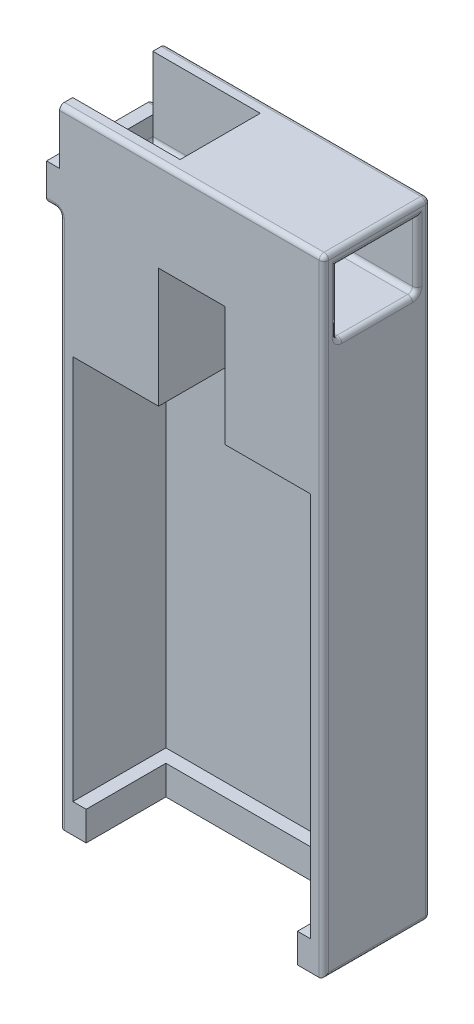
from build123d import *

# Parameters (mm, degrees)
SKETCH1_W            = 2.54
SKETCH1_H            = 2.54
BOSS_EXTRUDE3_DEPTH  = 5.588
BOSS_EXTRUDE4_START  = 5.588
BOSS_EXTRUDE4_DEPTH  = 73.66
BOSS_EXTRUDE6_START  = 79.248
SKETCH1_8_W          = 2.54
SKETCH1_8_H          = 2.54
SKETCH1_8_W_2        = 13.843
BOSS_EXTRUDE6_DEPTH  = 22.86
BOSS_EXTRUDE7_START  = 102.108
SKETCH1_9_W          = 12.7
SKETCH1_9_H          = 2.54
SKETCH1_9_W_2        = 2.54
SKETCH1_9_W_3        = 13.843
BOSS_EXTRUDE7_DEPTH  = 2.54
SKETCH2_W            = 50.546
SKETCH2_H            = 2.5
BOSS_EXTRUDE8_DEPTH  = 15
BOSS_EXTRUDE9_REACH  = 19.82
SKETCH3_W            = 30
SKETCH3_H            = 2.5
SKETCH4_W            = 20.32
SKETCH4_H            = 7
BOSS_EXTRUDE10_DEPTH = 2.5
FILLET1_R            = 0.905


with BuildPart() as part:
    # Sketch1 → Boss-Extrude3 (new body)
    with BuildSketch(Plane(origin=(0, 0, 0), x_dir=(1, 0, 0), z_dir=(0, 1, 0))):
        with BuildLine():
            Line((-22.733, -10.16), (-22.733, -7.62))
            Line((-22.733, -7.62), (-22.733, 7.62))
            Line((-22.733, 7.62), (-5.08, 7.62))
            ThreePointArc((-5.08, 7.62), (-2.839806331, 9.489612663), (0, 10.16))
            Line((0, 10.16), (-25.273, 10.16))
            Line((-25.273, 10.16), (-25.273, -10.16))
            Line((-25.273, -10.16), (-22.733, -10.16))
        make_face()
        with BuildLine():
            ThreePointArc((0, 10.16), (2.839806331, 9.489612663), (5.08, 7.62))
            Line((5.08, 7.62), (22.733, 7.62))
            Line((22.733, 7.62), (22.733, -7.62))
            Line((22.733, -7.62), (22.733, -10.16))
            Line((22.733, -10.16), (25.273, -10.16))
            Line((25.273, -10.16), (25.273, 10.16))
            Line((25.273, 10.16), (0, 10.16))
        make_face()
        with BuildLine():
            ThreePointArc((0, 10.16), (-2.839806331, 9.489612663), (-5.08, 7.62))
            Line((-5.08, 7.62), (5.08, 7.62))
            ThreePointArc((5.08, 7.62), (2.839806331, 9.489612663), (0, 10.16))
        make_face()
        with BuildLine():
            Line((-22.733, 7.62), (-22.733, -7.62))
            Line((-22.733, -7.62), (-20.193, -7.62))
            Line((-20.193, -7.62), (-20.193, -5.08))
            Line((-20.193, -5.08), (-20.193, 5.08))
            Line((-20.193, 5.08), (-6.221703947, 5.08))
            ThreePointArc((-6.221703947, 5.08), (-5.791806974, 6.413357827), (-5.08, 7.62))
            Line((-5.08, 7.62), (-22.733, 7.62))
        make_face()
        with Locations((-21.463, -8.89)):
            Rectangle(SKETCH1_W, SKETCH1_H)
        with BuildLine():
            Line((5.08, 7.62), (-5.08, 7.62))
            ThreePointArc((-5.08, 7.62), (-5.791806974, 6.413357827), (-6.221703947, 5.08))
            Line((-6.221703947, 5.08), (6.221703947, 5.08))
            ThreePointArc((6.221703947, 5.08), (5.791806974, 6.413357827), (5.08, 7.62))
        make_face()
        with BuildLine():
            Line((22.733, 7.62), (5.08, 7.62))
            ThreePointArc((5.08, 7.62), (5.791806974, 6.413357827), (6.221703947, 5.08))
            Line((6.221703947, 5.08), (20.193, 5.08))
            Line((20.193, 5.08), (20.193, -5.08))
            Line((20.193, -5.08), (20.193, -7.62))
            Line((20.193, -7.62), (22.733, -7.62))
            Line((22.733, -7.62), (22.733, 7.62))
        make_face()
        with Locations((21.463, -8.89)):
            Rectangle(SKETCH1_W, SKETCH1_H)
    extrude(amount=BOSS_EXTRUDE3_DEPTH)

    # Sketch1_7 → Boss-Extrude4 (add)
    with BuildSketch(Plane(origin=(0, 0, 0), x_dir=(1, 0, 0), z_dir=(0, 1, 0)).offset(BOSS_EXTRUDE4_START)):
        with BuildLine():
            Line((-22.733, -10.16), (-22.733, -7.62))
            Line((-22.733, -7.62), (-22.733, 7.62))
            Line((-22.733, 7.62), (-5.08, 7.62))
            ThreePointArc((-5.08, 7.62), (-2.839806331, 9.489612663), (0, 10.16))
            Line((0, 10.16), (-25.273, 10.16))
            Line((-25.273, 10.16), (-25.273, -10.16))
            Line((-25.273, -10.16), (-22.733, -10.16))
        make_face()
        with BuildLine():
            ThreePointArc((0, 10.16), (2.839806331, 9.489612663), (5.08, 7.62))
            Line((5.08, 7.62), (22.733, 7.62))
            Line((22.733, 7.62), (22.733, -7.62))
            Line((22.733, -7.62), (22.733, -10.16))
            Line((22.733, -10.16), (25.273, -10.16))
            Line((25.273, -10.16), (25.273, 10.16))
            Line((25.273, 10.16), (0, 10.16))
        make_face()
        with BuildLine():
            ThreePointArc((0, 10.16), (-2.839806331, 9.489612663), (-5.08, 7.62))
            Line((-5.08, 7.62), (5.08, 7.62))
            ThreePointArc((5.08, 7.62), (2.839806331, 9.489612663), (0, 10.16))
        make_face()
    extrude(amount=BOSS_EXTRUDE4_DEPTH)

    # Sketch1_8 → Boss-Extrude6 (add)
    with BuildSketch(Plane(origin=(0, 0, 0), x_dir=(1, 0, 0), z_dir=(0, 1, 0)).offset(BOSS_EXTRUDE6_START)):
        with BuildLine():
            Line((-22.733, -10.16), (-22.733, -7.62))
            Line((-22.733, -7.62), (-22.733, 7.62))
            Line((-22.733, 7.62), (-5.08, 7.62))
            ThreePointArc((-5.08, 7.62), (-2.839806331, 9.489612663), (0, 10.16))
            Line((0, 10.16), (-25.273, 10.16))
            Line((-25.273, 10.16), (-25.273, -10.16))
            Line((-25.273, -10.16), (-22.733, -10.16))
        make_face()
        with BuildLine():
            Line((-22.733, 7.62), (-22.733, -7.62))
            Line((-22.733, -7.62), (-20.193, -7.62))
            Line((-20.193, -7.62), (-20.193, -5.08))
            Line((-20.193, -5.08), (-20.193, 5.08))
            Line((-20.193, 5.08), (-6.221703947, 5.08))
            ThreePointArc((-6.221703947, 5.08), (-5.791806974, 6.413357827), (-5.08, 7.62))
            Line((-5.08, 7.62), (-22.733, 7.62))
        make_face()
        with BuildLine():
            Line((-20.193, -5.08), (-20.193, -7.62))
            Line((-20.193, -7.62), (-6.35, -7.62))
            Line((-6.35, -7.62), (-6.35, -3.175))
            Line((-6.35, -3.175), (-6.35, 3.81))
            ThreePointArc((-6.35, 3.81), (-6.317844572, 4.448231909), (-6.221703947, 5.08))
            Line((-6.221703947, 5.08), (-20.193, 5.08))
            Line((-20.193, 5.08), (-20.193, -5.08))
        make_face()
        with Locations((-21.463, -8.89)):
            Rectangle(SKETCH1_8_W, SKETCH1_8_H)
        with Locations((-13.2715, -8.89)):
            Rectangle(SKETCH1_8_W_2, SKETCH1_8_H)
        with BuildLine():
            ThreePointArc((0, 10.16), (2.839806331, 9.489612663), (5.08, 7.62))
            Line((5.08, 7.62), (22.733, 7.62))
            Line((22.733, 7.62), (22.733, -7.62))
            Line((22.733, -7.62), (22.733, -10.16))
            Line((22.733, -10.16), (25.273, -10.16))
            Line((25.273, -10.16), (25.273, 10.16))
            Line((25.273, 10.16), (0, 10.16))
        make_face()
        with BuildLine():
            Line((22.733, 7.62), (5.08, 7.62))
            ThreePointArc((5.08, 7.62), (5.791806974, 6.413357827), (6.221703947, 5.08))
            Line((6.221703947, 5.08), (20.193, 5.08))
            Line((20.193, 5.08), (20.193, -5.08))
            Line((20.193, -5.08), (20.193, -7.62))
            Line((20.193, -7.62), (22.733, -7.62))
            Line((22.733, -7.62), (22.733, 7.62))
        make_face()
        with BuildLine():
            Line((6.35, -3.175), (6.35, -7.62))
            Line((6.35, -7.62), (20.193, -7.62))
            Line((20.193, -7.62), (20.193, -5.08))
            Line((20.193, -5.08), (20.193, 5.08))
            Line((20.193, 5.08), (6.221703947, 5.08))
            ThreePointArc((6.221703947, 5.08), (6.317844572, 4.448231909), (6.35, 3.81))
            Line((6.35, 3.81), (6.35, -3.175))
        make_face()
        with Locations((13.2715, -8.89)):
            Rectangle(SKETCH1_8_W_2, SKETCH1_8_H)
        with Locations((21.463, -8.89)):
            Rectangle(SKETCH1_8_W, SKETCH1_8_H)
        with BuildLine():
            ThreePointArc((0, 10.16), (-2.839806331, 9.489612663), (-5.08, 7.62))
            Line((-5.08, 7.62), (5.08, 7.62))
            ThreePointArc((5.08, 7.62), (2.839806331, 9.489612663), (0, 10.16))
        make_face()
    extrude(amount=BOSS_EXTRUDE6_DEPTH)

    # Sketch1_9 → Boss-Extrude7 (add)
    with BuildSketch(Plane(origin=(0, 0, 0), x_dir=(1, 0, 0), z_dir=(0, 1, 0)).offset(BOSS_EXTRUDE7_START)):
        with BuildLine():
            Line((-6.35, -3.175), (-6.35, -7.62))
            Line((-6.35, -7.62), (6.35, -7.62))
            Line((6.35, -7.62), (6.35, -3.175))
            Line((6.35, -3.175), (6.35, 3.81))
            ThreePointArc((6.35, 3.81), (6.317844572, 4.448231909), (6.221703947, 5.08))
            Line((6.221703947, 5.08), (-6.221703947, 5.08))
            ThreePointArc((-6.221703947, 5.08), (-6.317844572, 4.448231909), (-6.35, 3.81))
            Line((-6.35, 3.81), (-6.35, -3.175))
        make_face()
        with Locations((0, -8.89)):
            Rectangle(SKETCH1_9_W, SKETCH1_9_H)
        with BuildLine():
            Line((5.08, 7.62), (-5.08, 7.62))
            ThreePointArc((-5.08, 7.62), (-5.791806974, 6.413357827), (-6.221703947, 5.08))
            Line((-6.221703947, 5.08), (6.221703947, 5.08))
            ThreePointArc((6.221703947, 5.08), (5.791806974, 6.413357827), (5.08, 7.62))
        make_face()
        with BuildLine():
            Line((-22.733, -10.16), (-22.733, -7.62))
            Line((-22.733, -7.62), (-22.733, 7.62))
            Line((-22.733, 7.62), (-5.08, 7.62))
            ThreePointArc((-5.08, 7.62), (-2.839806331, 9.489612663), (0, 10.16))
            Line((0, 10.16), (-25.273, 10.16))
            Line((-25.273, 10.16), (-25.273, -10.16))
            Line((-25.273, -10.16), (-22.733, -10.16))
        make_face()
        with Locations((-21.463, -8.89)):
            Rectangle(SKETCH1_9_W_2, SKETCH1_9_H)
        with BuildLine():
            Line((-22.733, 7.62), (-22.733, -7.62))
            Line((-22.733, -7.62), (-20.193, -7.62))
            Line((-20.193, -7.62), (-20.193, -5.08))
            Line((-20.193, -5.08), (-20.193, 5.08))
            Line((-20.193, 5.08), (-6.221703947, 5.08))
            ThreePointArc((-6.221703947, 5.08), (-5.791806974, 6.413357827), (-5.08, 7.62))
            Line((-5.08, 7.62), (-22.733, 7.62))
        make_face()
        with Locations((-13.2715, -8.89)):
            Rectangle(SKETCH1_9_W_3, SKETCH1_9_H)
        with BuildLine():
            Line((-20.193, -5.08), (-20.193, -7.62))
            Line((-20.193, -7.62), (-6.35, -7.62))
            Line((-6.35, -7.62), (-6.35, -3.175))
            Line((-6.35, -3.175), (-6.35, 3.81))
            ThreePointArc((-6.35, 3.81), (-6.317844572, 4.448231909), (-6.221703947, 5.08))
            Line((-6.221703947, 5.08), (-20.193, 5.08))
            Line((-20.193, 5.08), (-20.193, -5.08))
        make_face()
        with BuildLine():
            ThreePointArc((0, 10.16), (-2.839806331, 9.489612663), (-5.08, 7.62))
            Line((-5.08, 7.62), (5.08, 7.62))
            ThreePointArc((5.08, 7.62), (2.839806331, 9.489612663), (0, 10.16))
        make_face()
        with BuildLine():
            Line((22.733, 7.62), (5.08, 7.62))
            ThreePointArc((5.08, 7.62), (5.791806974, 6.413357827), (6.221703947, 5.08))
            Line((6.221703947, 5.08), (20.193, 5.08))
            Line((20.193, 5.08), (20.193, -5.08))
            Line((20.193, -5.08), (20.193, -7.62))
            Line((20.193, -7.62), (22.733, -7.62))
            Line((22.733, -7.62), (22.733, 7.62))
        make_face()
        with BuildLine():
            ThreePointArc((0, 10.16), (2.839806331, 9.489612663), (5.08, 7.62))
            Line((5.08, 7.62), (22.733, 7.62))
            Line((22.733, 7.62), (22.733, -7.62))
            Line((22.733, -7.62), (22.733, -10.16))
            Line((22.733, -10.16), (25.273, -10.16))
            Line((25.273, -10.16), (25.273, 10.16))
            Line((25.273, 10.16), (0, 10.16))
        make_face()
        with BuildLine():
            Line((6.35, -3.175), (6.35, -7.62))
            Line((6.35, -7.62), (20.193, -7.62))
            Line((20.193, -7.62), (20.193, -5.08))
            Line((20.193, -5.08), (20.193, 5.08))
            Line((20.193, 5.08), (6.221703947, 5.08))
            ThreePointArc((6.221703947, 5.08), (6.317844572, 4.448231909), (6.35, 3.81))
            Line((6.35, 3.81), (6.35, -3.175))
        make_face()
        with Locations((13.2715, -8.89)):
            Rectangle(SKETCH1_9_W_3, SKETCH1_9_H)
        with Locations((21.463, -8.89)):
            Rectangle(SKETCH1_9_W_2, SKETCH1_9_H)
    extrude(amount=BOSS_EXTRUDE7_DEPTH)

    # Sketch2 → Boss-Extrude8 (add)
    with BuildSketch(Plane(origin=(0, 104.648, 0), x_dir=(1, 0, 0), z_dir=(0, 1, 0))):
        with Locations((0, 8.91)):
            Rectangle(SKETCH2_W, SKETCH2_H)
        with Locations((0, -8.91)):
            Rectangle(SKETCH2_W, SKETCH2_H)
    extrude(amount=BOSS_EXTRUDE8_DEPTH)

    # Sketch3 → Boss-Extrude9 (add, up to next)
    with BuildSketch(Plane.XY.offset(-7.66), mode=Mode.PRIVATE) as boss_extrude9_sk1:
        with Locations((10.273, 118.398)):
            Rectangle(SKETCH3_W, SKETCH3_H)
    boss_extrude9_tool1 = extrude(boss_extrude9_sk1.sketch, amount=BOSS_EXTRUDE9_REACH, mode=Mode.PRIVATE) - part.part
    add(boss_extrude9_tool1.solids().sort_by_distance((10.273, 118.398, -7.66))[0])

    # Sketch4 → Boss-Extrude10 (add)
    with BuildSketch(Plane.ZY.offset(25.273)):
        with Locations((0, 105.648)):
            Rectangle(SKETCH4_W, SKETCH4_H)
    extrude(amount=BOSS_EXTRUDE10_DEPTH)

    # Fillet1
    fillet1_edges = [part.edges().sort_by_distance(p)[0] for p in [
        (-25.273, 104.648, 0),
        (25.273, 104.648, 0),
        (0, 104.648, -7.66),
        (0, 119.648, -10.16),
        (25.273, 119.648, 0),
        (0, 104.648, 7.66),
        (0, 119.648, 10.16),
        (-25.273, 0, 0),
        (0, 0, -10.16),
        (25.273, 0, 0),
        (25.273, 110.898, -7.66),
        (25.273, 110.898, 7.66),
        (25.273, 117.148, 0),
        (-25.273, 51.074, 10.16),
        (-25.273, 51.074, -10.16),
        (-26.523, 109.148, -10.16),
        (-25.273, 102.148, 0),
        (-26.523, 102.148, -10.16),
        (-26.523, 102.148, 10.16),
        (-27.773, 105.648, -10.16),
        (-25.273, 114.398, -10.16),
        (25.273, 59.824, -10.16),
        (25.273, 59.824, 10.16),
    ]]
    fillet(fillet1_edges, radius=FILLET1_R)


solid = part.part
